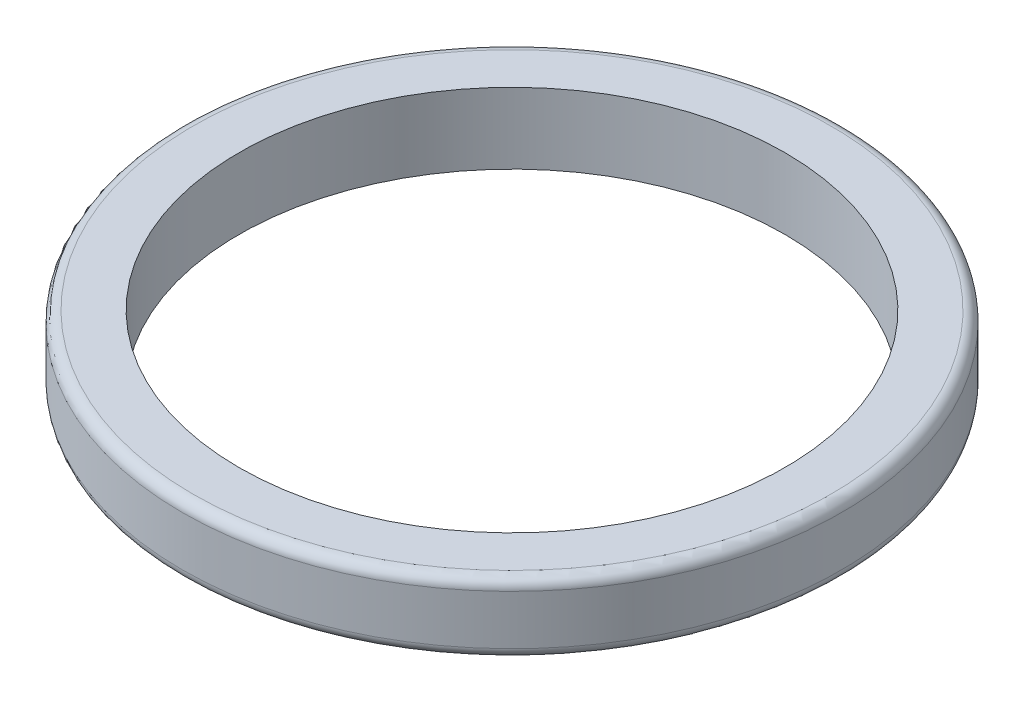
from build123d import *

# Parameters (mm, degrees)
SKETCH1_R           = 15.5
SKETCH1_R_2         = 12.833333333
BOSS_EXTRUDE2_DEPTH = 3.333333333
FILLET1_R           = 0.5


with BuildPart() as part:
    # Sketch1 → Boss-Extrude2 (new body)
    with BuildSketch(Plane(origin=(0, 0, 0), x_dir=(1, 0, 0), z_dir=(0, 1, 0))):
        Circle(SKETCH1_R)
        Circle(SKETCH1_R_2, mode=Mode.SUBTRACT)
    extrude(amount=BOSS_EXTRUDE2_DEPTH)

    # Fillet1
    fillet1_edges = [part.edges().sort_by_distance(p)[0] for p in [
        (-15.5, 0, 0),
        (-15.5, 3.333333333, 0),
    ]]
    fillet(fillet1_edges, radius=FILLET1_R)


solid = part.part
